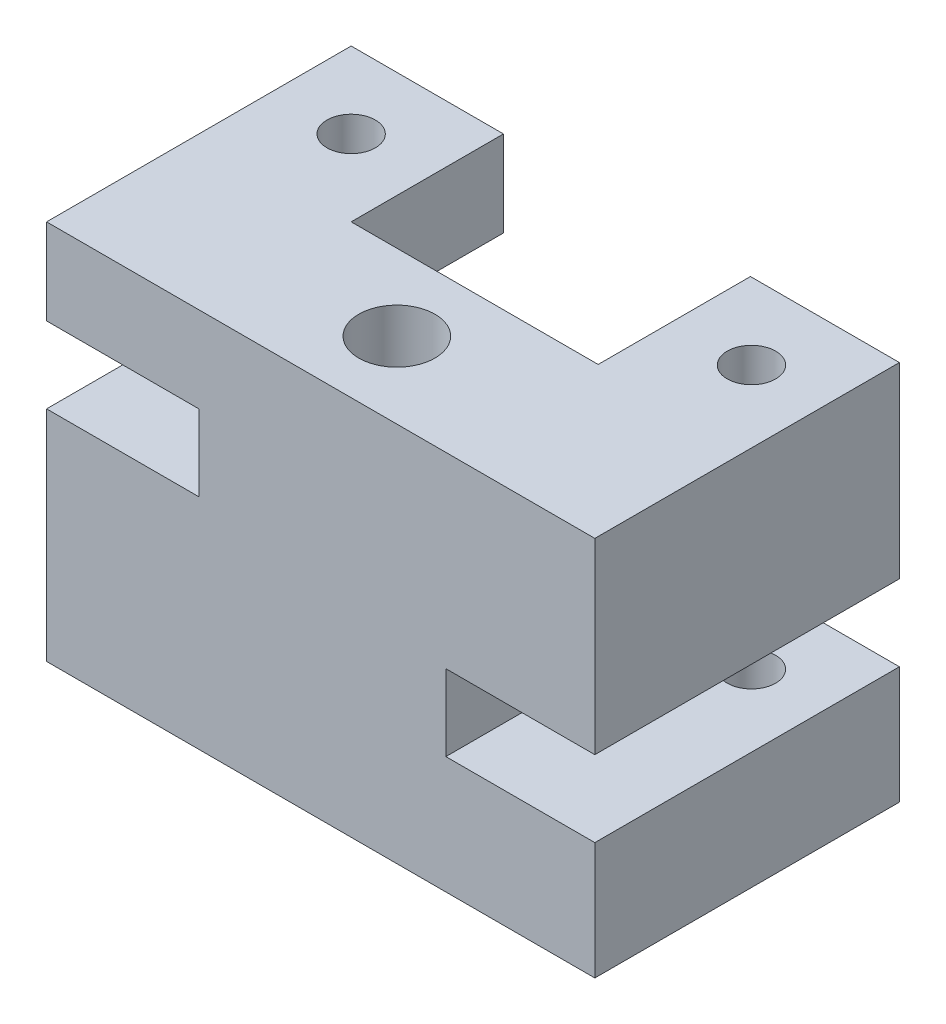
from build123d import *

# Parameters (mm, degrees)
BOSS_EXTRUDE1_DEPTH = 30
SKETCH3_R           = 7.5
CUT_EXTRUDE3_DEPTH  = 76
SKETCH4_W           = 29.345301095
SKETCH4_H           = 36.901717618
SKETCH4_H_2         = 23.098282382
SKETCH4_W_2         = 30
SKETCH4_H_3         = 43.098282382
SKETCH4_H_4         = 16.901717618
BOSS_EXTRUDE2_DEPTH = 30
SKETCH2_R           = 4.7625
CUT_EXTRUDE2_DEPTH  = 61.901718
SKETCH5_R           = 4.7625
CUT_EXTRUDE4_DEPTH  = 41.901718


with BuildPart() as part:
    # Sketch1 → Boss-Extrude1 (new body)
    with BuildSketch(Plane.XY):
        Polygon((-54, 34.401717618), (54, 34.401717618), (54, -2.5), (24.654698905, -2.5), (24.654698905, -17.5), (54, -17.5), (54, -40.598282382), (-54, -40.598282382), (-54, 2.5), (-24, 2.5), (-24, 17.5), (-54, 17.5), align=None)
    extrude(amount=BOSS_EXTRUDE1_DEPTH)

    # Sketch3 → Cut-Extrude3 (cut, through all)
    with BuildSketch(Plane(origin=(0, 34.401717618, 0), x_dir=(1, 0, 0), z_dir=(0, 1, 0))):
        with Locations((0, -15)):
            Circle(SKETCH3_R)
    extrude(amount=-CUT_EXTRUDE3_DEPTH, mode=Mode.SUBTRACT)

    # Sketch4 → Boss-Extrude2 (add)
    with BuildSketch(Plane(origin=(0, 0, 0), x_dir=(-1, 0, 0), z_dir=(0, 0, -1))):
        with Locations((-39.327349453, 15.950858809)):
            Rectangle(SKETCH4_W, SKETCH4_H)
        with Locations((-39.327349453, -29.049141191)):
            Rectangle(SKETCH4_W, SKETCH4_H_2)
        with Locations((39, -19.049141191)):
            Rectangle(SKETCH4_W_2, SKETCH4_H_3)
        with Locations((39, 25.950858809)):
            Rectangle(SKETCH4_W_2, SKETCH4_H_4)
    extrude(amount=BOSS_EXTRUDE2_DEPTH)

    # Sketch2 → Cut-Extrude2 (cut)
    with BuildSketch(Plane(origin=(0, 34.401717618, 0), x_dir=(1, 0, 0), z_dir=(0, 1, 0))):
        with Locations((39.853186988, 15)):
            Circle(SKETCH2_R)
    extrude(amount=-CUT_EXTRUDE2_DEPTH, mode=Mode.SUBTRACT)

    # Sketch5 → Cut-Extrude4 (cut)
    with BuildSketch(Plane(origin=(0, 34.401717618, 0), x_dir=(1, 0, 0), z_dir=(0, 1, 0))):
        with Locations((-39, 15)):
            Circle(SKETCH5_R)
    extrude(amount=-CUT_EXTRUDE4_DEPTH, mode=Mode.SUBTRACT)


solid = part.part
